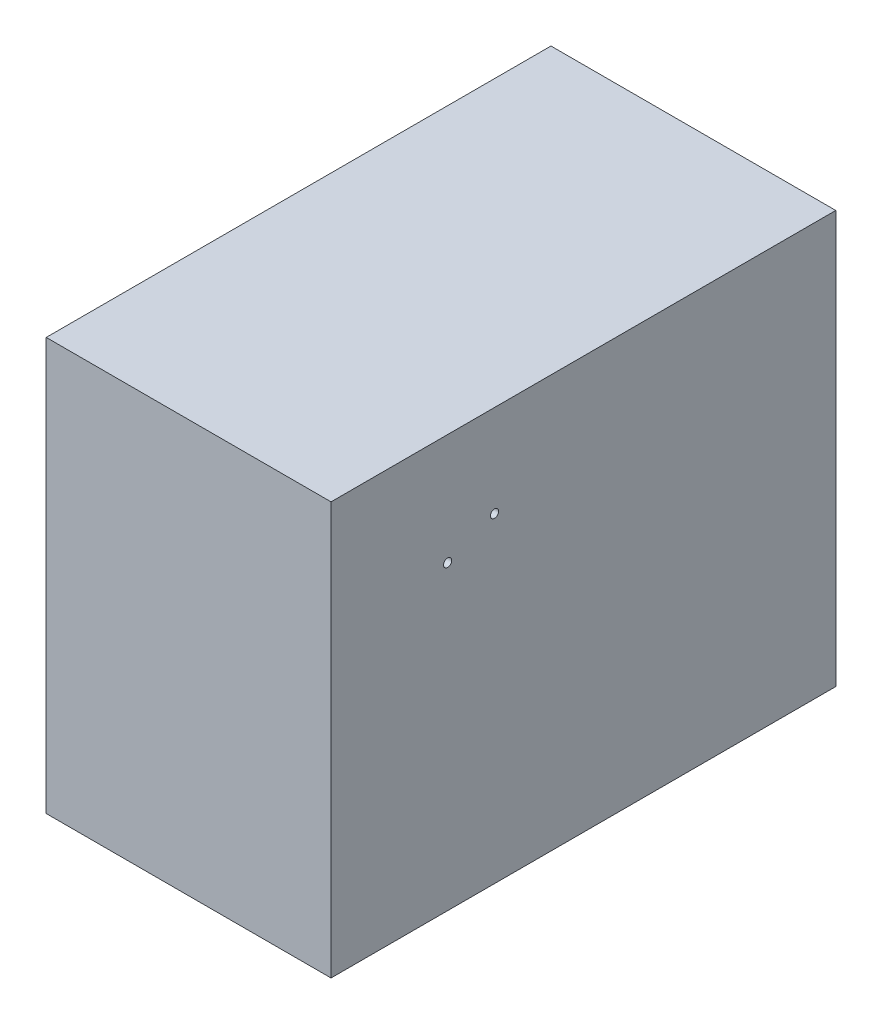
from build123d import *

# Parameters (mm, degrees)
SKETCH1_W           = 100.33
SKETCH1_H           = 145.2626
BOSS_EXTRUDE1_DEPTH = 177.8
SKETCH2_R           = 1.4478
CUT_EXTRUDE1_DEPTH  = 177.8


with BuildPart() as part:
    # Sketch1 → Boss-Extrude1 (new body)
    with BuildSketch(Plane.XY):
        Rectangle(SKETCH1_W, SKETCH1_H)
    extrude(amount=BOSS_EXTRUDE1_DEPTH)

    # Sketch2 → Cut-Extrude1 (cut)
    with BuildSketch(Plane(origin=(50.165, 0, 0), x_dir=(0, 0, -1), z_dir=(1, 0, 0))):
        with Locations((-136.7282, 33.5407)):
            Circle(SKETCH2_R)
        with Locations((-120.2182, 40.2463)):
            Circle(SKETCH2_R)
    extrude(amount=-CUT_EXTRUDE1_DEPTH, mode=Mode.SUBTRACT)


solid = part.part
